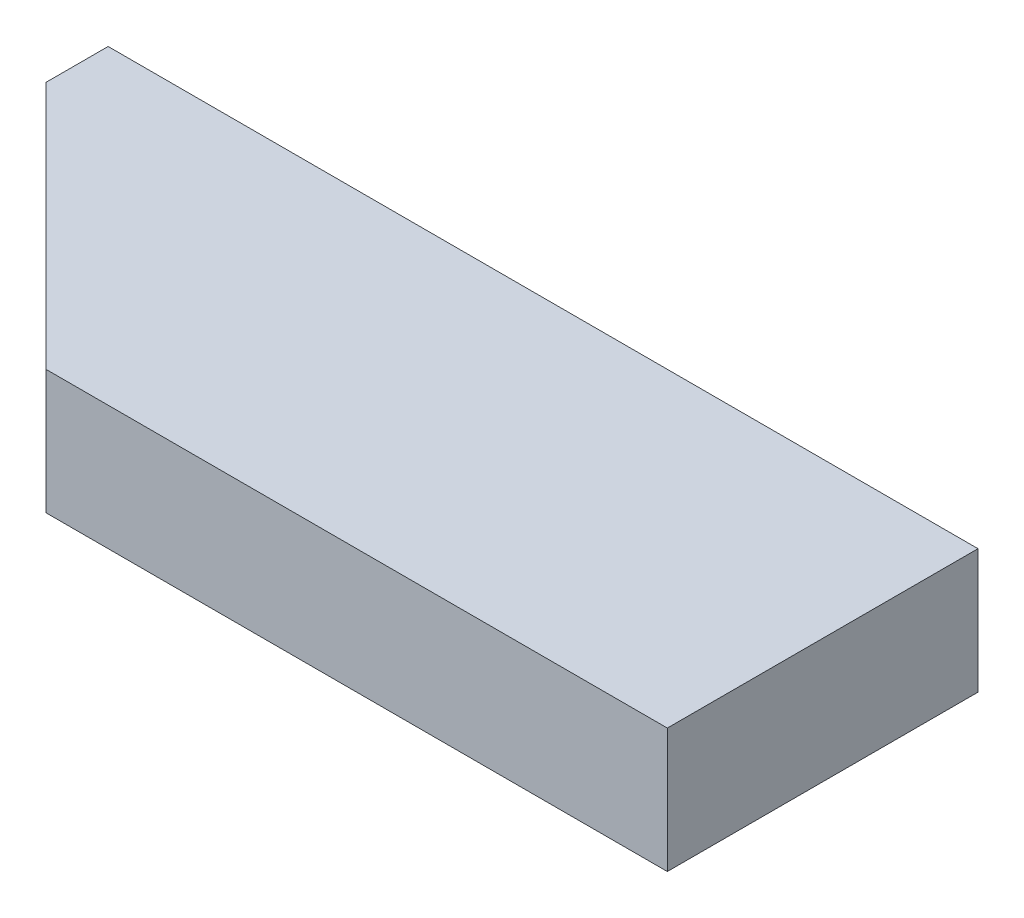
from build123d import *

# Parameters (mm, degrees)
SKETCH2_W           = 70
SKETCH2_H           = 25
BOSS_EXTRUDE1_DEPTH = 10
CHAMFER2_SIZE       = 20


with BuildPart() as part:
    # Sketch2 → Boss-Extrude1 (new body)
    with BuildSketch(Plane(origin=(0, 0, 0), x_dir=(1, 0, 0), z_dir=(0, 1, 0))):
        Rectangle(SKETCH2_W, SKETCH2_H)
    extrude(amount=BOSS_EXTRUDE1_DEPTH)

    # Chamfer2
    chamfer2_edges = [part.edges().sort_by_distance(p)[0] for p in [
        (-35, 5, 12.5),
    ]]
    chamfer(chamfer2_edges, length=CHAMFER2_SIZE)


solid = part.part
